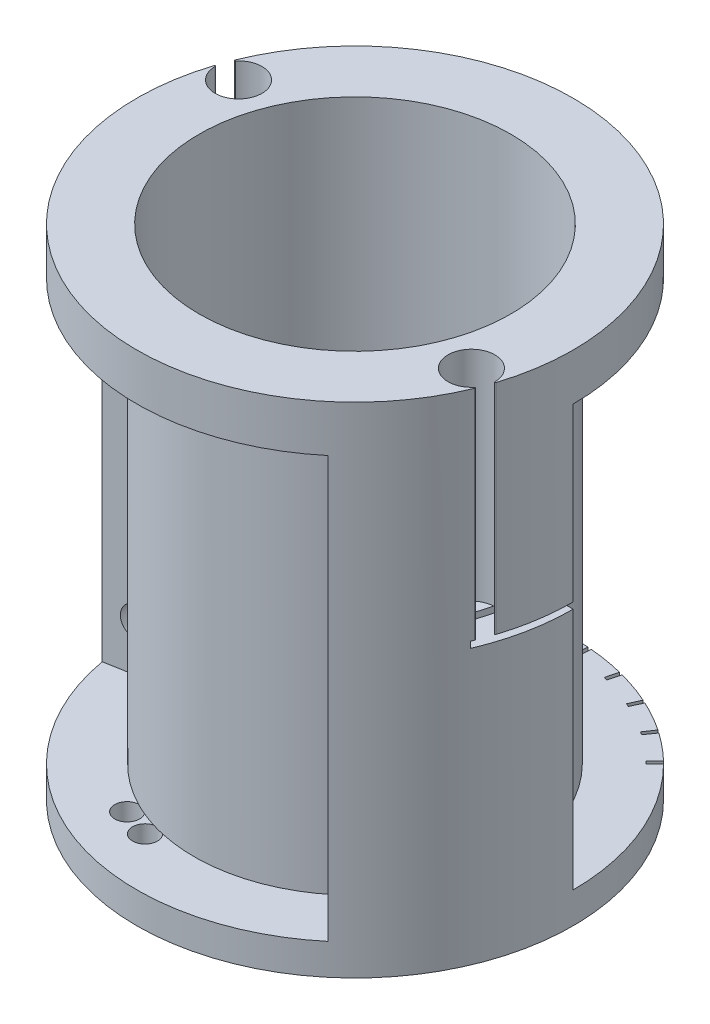
from build123d import *

# Parameters (mm, degrees)
SKETCH1_W                    = 25.4
SKETCH1_H                    = 203.2
SKETCH2_W                    = 23.400004
SKETCH2_H                    = 171.45
CUT_REVOLVE1_ANGLE           = 140
SKETCH5_R                    = 9.525
CUT_EXTRUDE1_DEPTH           = 88.9
SKETCH7_W                    = 12.7
SKETCH7_H                    = 2.54
CUT_REVOLVE3_ANGLE           = 23
FILLET2_R                    = 0.254
FILLET2_OF_MIRROR1_R         = 0.254
CUT_EXTRUDE6_DEPTH           = 12.7
CIRPATTERN1_COUNT            = 6
CIRPATTERN1_ANGLE            = 50
SKETCH12_R                   = 5.08
CUT_EXTRUDE7_DEPTH           = 12.7
SKETCH16_W                   = 23.368
SKETCH16_H                   = 171.45
CUT_REVOLVE4_ANGLE           = 60
CUT_REVOLVE4_OTHER_WAY_ANGLE = 60
SKETCH17_R                   = 6.35


with BuildPart() as part:
    # Sketch1 → Revolve1 (revolve)
    with BuildSketch(Plane.XY):
        with Locations((76.2, 101.6)):
            Rectangle(SKETCH1_W, SKETCH1_H)
    revolve(axis=Axis((0, 0, 0), (0, 1, 0)))

    # Sketch2 → Cut-Revolve1 (revolve, cut)
    with BuildSketch(Plane.XY):
        with Locations((77.199998, 98.425)):
            Rectangle(SKETCH2_W, SKETCH2_H)
    revolve(axis=Axis((0, 0, 0), (0, 1, 0)), revolution_arc=CUT_REVOLVE1_ANGLE, mode=Mode.SUBTRACT)

    # Sketch5 → Cut-Extrude1 (cut)
    with BuildSketch(Plane(origin=(0, 203.2, 0), x_dir=(1, 0, 0), z_dir=(0, 1, 0))):
        with Locations((-74.600035871, 27.152192532)):
            Circle(SKETCH5_R)
    cut_extrude1 = extrude(amount=-CUT_EXTRUDE1_DEPTH, mode=Mode.SUBTRACT)

    # Sketch7 → Cut-Revolve3 (revolve, cut)
    with BuildSketch(Plane(origin=(0, 0, 0), x_dir=(-0.766044443, 0, -0.64278761), z_dir=(0.64278761, 0, -0.766044443))):
        with Locations((82.55, 113.03)):
            Rectangle(SKETCH7_W, SKETCH7_H)
    cut_revolve3 = revolve(axis=Axis((0, 213.36, 0), (0, 1, 0)), revolution_arc=CUT_REVOLVE3_ANGLE, mode=Mode.SUBTRACT)

    # Fillet2
    fillet2_edges = [part.edges().sort_by_distance(p)[0] for p in [
        (-83.359280525, 158.75, -30.894018036),
        (-83.715205635, 158.75, -29.916121832),
    ]]
    fillet(fillet2_edges, radius=FILLET2_R)

    # Mirror1: Cut-Extrude1, Cut-Revolve3 across plane
    add(cut_extrude1.mirror(Plane(origin=(0, 0, 0), x_dir=(-0.342020143, 0, 0.939692621), z_dir=(-0.939692621, 0, -0.342020143))), mode=Mode.SUBTRACT)
    add(cut_revolve3.mirror(Plane(origin=(0, 0, 0), x_dir=(-0.342020143, 0, 0.939692621), z_dir=(-0.939692621, 0, -0.342020143))), mode=Mode.SUBTRACT)

    # Fillet2 of Mirror1
    fillet2_of_mirror1_edges = [part.edges().sort_by_distance(p)[0] for p in [
        (83.715205635, 158.75, 29.916121832),
        (83.359280525, 158.75, 30.894018036),
    ]]
    fillet(fillet2_of_mirror1_edges, radius=FILLET2_OF_MIRROR1_R)

    # Sketch15 → Cut-Extrude6 (cut)
    with BuildSketch(Plane(origin=(0, 12.7, 0), x_dir=(1, 0, 0), z_dir=(0, 1, 0))):
        with BuildLine():
            Line((59.269690399, 59.269690399), (62.861792847, 62.861792847))
            ThreePointArc((62.861792847, 62.861792847), (62.310833596, 63.40796493), (61.755129134, 63.94930825))
            Line((61.755129134, 63.94930825), (58.226264612, 60.295062064))
            ThreePointArc((58.226264612, 60.295062064), (58.750214534, 59.784652648), (59.269690399, 59.269690399))
        make_face()
    cut_extrude6 = extrude(amount=-CUT_EXTRUDE6_DEPTH, mode=Mode.SUBTRACT)

    # CirPattern1: Cut-Extrude6 ×6 about axis
    cirpattern1_axis = Axis((0, 0, 0), (0, 1, 0))
    for i in range(1, CIRPATTERN1_COUNT):
        add(cut_extrude6.rotate(cirpattern1_axis, i * CIRPATTERN1_ANGLE / (CIRPATTERN1_COUNT - 1)), mode=Mode.SUBTRACT)

    # Sketch12 → Cut-Extrude7 (cut)
    with BuildSketch(Plane(origin=(0, 12.7, 0), x_dir=(1, 0, 0), z_dir=(0, 1, 0))):
        with Locations((-29.519885583, -63.305598925)):
            Circle(SKETCH12_R)
        with Locations((-18.0785103, -67.469918966)):
            Circle(SKETCH12_R)
    extrude(amount=-CUT_EXTRUDE7_DEPTH, mode=Mode.SUBTRACT)

    # Sketch16 → Cut-Revolve4 (revolve, cut)
    with BuildSketch(Plane(origin=(0, 0, 0), x_dir=(-0.342020143, 0, 0.939692621), z_dir=(-0.939692621, 0, -0.342020143))):
        with Locations((77.216, 98.425)):
            Rectangle(SKETCH16_W, SKETCH16_H)
    revolve(axis=Axis((0, -7.62, 0), (0, 1, 0)), revolution_arc=CUT_REVOLVE4_ANGLE, mode=Mode.SUBTRACT)

    # Sketch16 → Cut-Revolve4 other way (revolve, cut)
    with BuildSketch(Plane(origin=(0, 0, 0), x_dir=(-0.342020143, 0, 0.939692621), z_dir=(-0.939692621, 0, -0.342020143))):
        with Locations((77.216, 98.425)):
            Rectangle(SKETCH16_W, SKETCH16_H)
    revolve(axis=Axis((0, -7.62, 0), (0, -1, 0)), revolution_arc=CUT_REVOLVE4_OTHER_WAY_ANGLE, mode=Mode.SUBTRACT)

    # Sketch17 → Cut-Revolve5 (revolve, cut)
    with BuildSketch(Plane(origin=(0, 0, 0), x_dir=(-0.342020143, 0, 0.939692621), z_dir=(-0.939692621, 0, -0.342020143))):
        with Locations((76.2, 31.75)):
            Circle(SKETCH17_R)
    revolve(axis=Axis((0, 213.36, 0), (0, -1, 0)), mode=Mode.SUBTRACT)


solid = part.part
